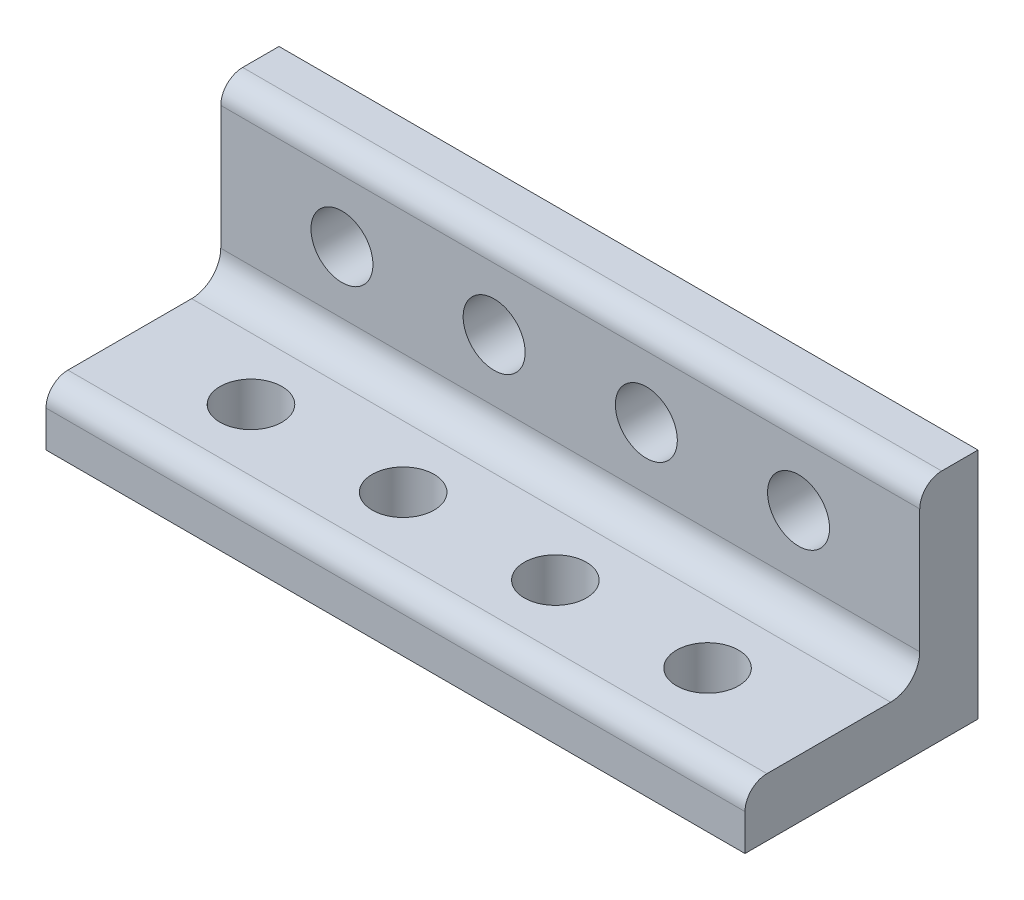
from build123d import *

# Parameters (mm, degrees)
SKETCH1_W           = 76.2
SKETCH1_H           = 25.4
BOSS_EXTRUDE1_DEPTH = 6.35
SKETCH2_W           = 76.2
SKETCH2_H           = 25.4
BOSS_EXTRUDE2_DEPTH = 6.35
FILLET1_R           = 3.175
FILLET2_R           = 2.3876
SKETCH3_R           = 3.3782
CUT_EXTRUDE1_DEPTH  = 7.35
SKETCH4_R           = 3.3782
CUT_EXTRUDE2_DEPTH  = 7.35


with BuildPart() as part:
    # Sketch1 → Boss-Extrude1 (new body)
    with BuildSketch(Plane(origin=(0, 0, 0), x_dir=(1, 0, 0), z_dir=(0, 1, 0))):
        with Locations((38.1, 12.7)):
            Rectangle(SKETCH1_W, SKETCH1_H)
    extrude(amount=BOSS_EXTRUDE1_DEPTH)

    # Sketch2 → Boss-Extrude2 (add)
    with BuildSketch(Plane(origin=(0, 0, -25.4), x_dir=(-1, 0, 0), z_dir=(0, 0, -1))):
        with Locations((-38.1, 12.7)):
            Rectangle(SKETCH2_W, SKETCH2_H)
    extrude(amount=-BOSS_EXTRUDE2_DEPTH)

    # Fillet1
    fillet1_edges = [part.edges().sort_by_distance(p)[0] for p in [
        (38.1, 6.35, -19.05),
    ]]
    fillet(fillet1_edges, radius=FILLET1_R)

    # Fillet2
    fillet2_edges = [part.edges().sort_by_distance(p)[0] for p in [
        (38.1, 25.4, -19.05),
        (38.1, 6.35, 0),
    ]]
    fillet(fillet2_edges, radius=FILLET2_R)

    # Sketch3 → Cut-Extrude1 (cut, through all)
    with BuildSketch(Plane(origin=(0, 6.35, 0), x_dir=(1, 0, 0), z_dir=(0, 1, 0))):
        with Locations((13.21308, 9.1313)):
            Circle(SKETCH3_R)
        with Locations((29.80436, 9.1313)):
            Circle(SKETCH3_R)
        with Locations((46.39564, 9.1313)):
            Circle(SKETCH3_R)
        with Locations((62.98692, 9.1313)):
            Circle(SKETCH3_R)
    extrude(amount=-CUT_EXTRUDE1_DEPTH, mode=Mode.SUBTRACT)

    # Sketch4 → Cut-Extrude2 (cut, through all)
    with BuildSketch(Plane.XY.offset(-19.05)):
        with Locations((13.21308, 16.2687)):
            Circle(SKETCH4_R)
        with Locations((29.80436, 16.2687)):
            Circle(SKETCH4_R)
        with Locations((46.39564, 16.2687)):
            Circle(SKETCH4_R)
        with Locations((62.98692, 16.2687)):
            Circle(SKETCH4_R)
    extrude(amount=-CUT_EXTRUDE2_DEPTH, mode=Mode.SUBTRACT)


solid = part.part
